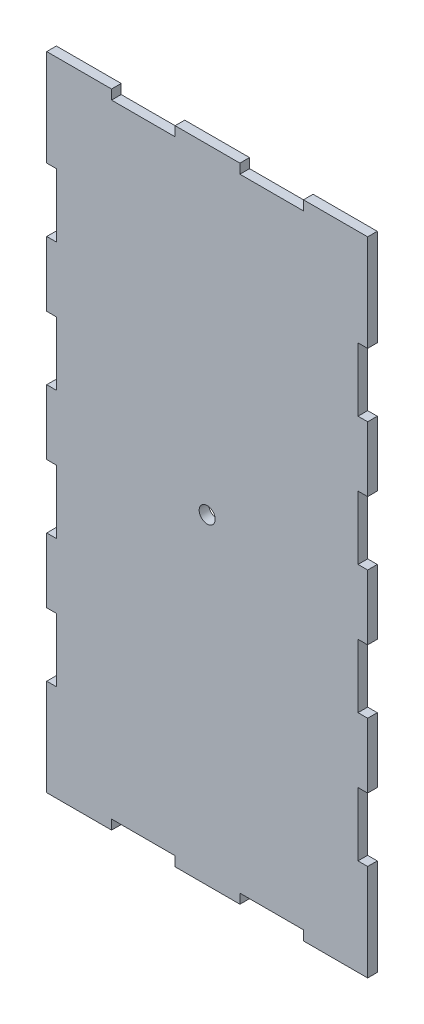
from build123d import *

# Parameters (mm, degrees)
SKETCH1_R           = 2.5
BOSS_EXTRUDE1_DEPTH = 3


with BuildPart() as part:
    # Sketch1 → Boss-Extrude1 (new body)
    with BuildSketch(Plane.XY):
        Polygon((60.2, 197), (60.2, 200), (40, 200), (40, 197), (20.2, 197), (20.2, 200), (0, 200), (0, 169.9), (3, 169.9), (3, 150.1), (0, 150.1), (0, 129.9), (3, 129.9), (3, 110.1), (0, 110.1), (0, 89.9), (3, 89.9), (3, 70.1), (0, 70.1), (0, 49.9), (3, 49.9), (3, 30.1), (0, 30.1), (0, 0), (20.2, 0), (20.2, 3), (40, 3), (40, 0), (60.2, 0), (60.2, 3), (80, 3), (80, 0), (100, 0), (100, 30.1), (97, 30.1), (97, 49.9), (100, 49.9), (100, 70.1), (97, 70.1), (97, 89.9), (100, 89.9), (100, 110.1), (97, 110.1), (97, 129.9), (100, 129.9), (100, 150.1), (97, 150.1), (97, 169.9), (100, 169.9), (100, 200), (80, 200), (80, 197), align=None)
        with Locations((50, 100)):
            Circle(SKETCH1_R, mode=Mode.SUBTRACT)
    extrude(amount=BOSS_EXTRUDE1_DEPTH)


solid = part.part
